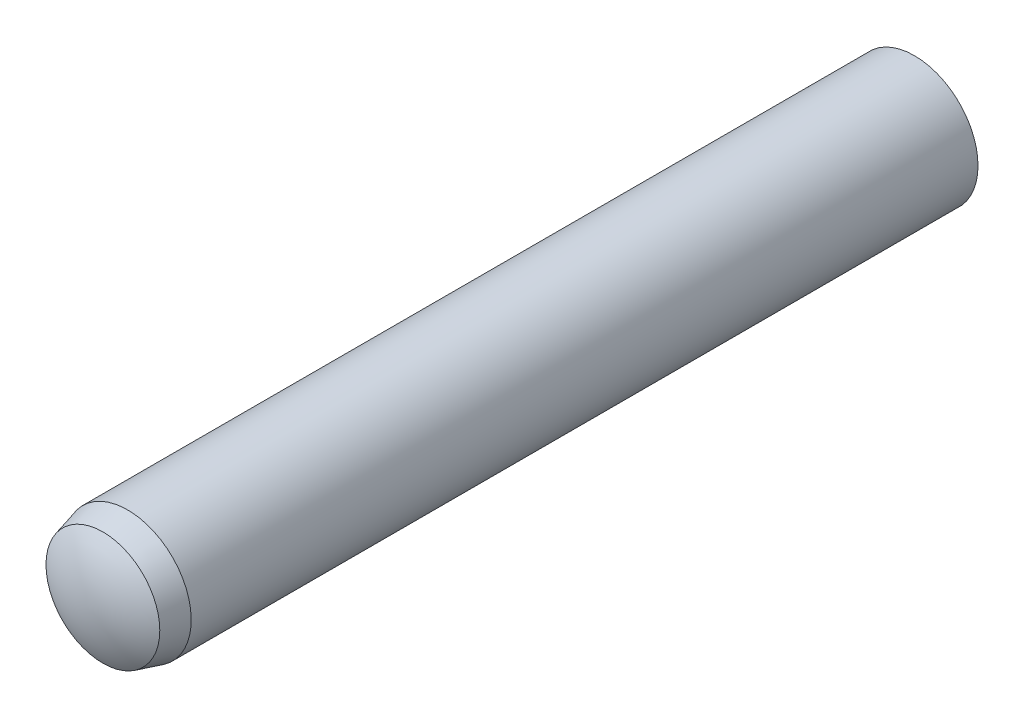
from build123d import *


with BuildPart() as part:
    # Sketch3 → Revolve1 (revolve)
    with BuildSketch(Plane(origin=(0, 0, 0), x_dir=(0, 0, -1), z_dir=(1, 0, 0))):
        with BuildLine():
            Line((-10, 0), (10, 0))
            ThreePointArc((10, 0), (9.885076627, 0.783022988), (9.55, 1.5))
            Line((9.55, 1.5), (-9.025, 1.5))
            Line((-9.025, 1.5), (-9.61, 1.343249722))
            ThreePointArc((-9.61, 1.343249722), (-9.90052754, 0.699360389), (-10, 0))
        make_face()
    revolve(axis=Axis((0, 0, 10), (0, 0, -1)))


solid = part.part
